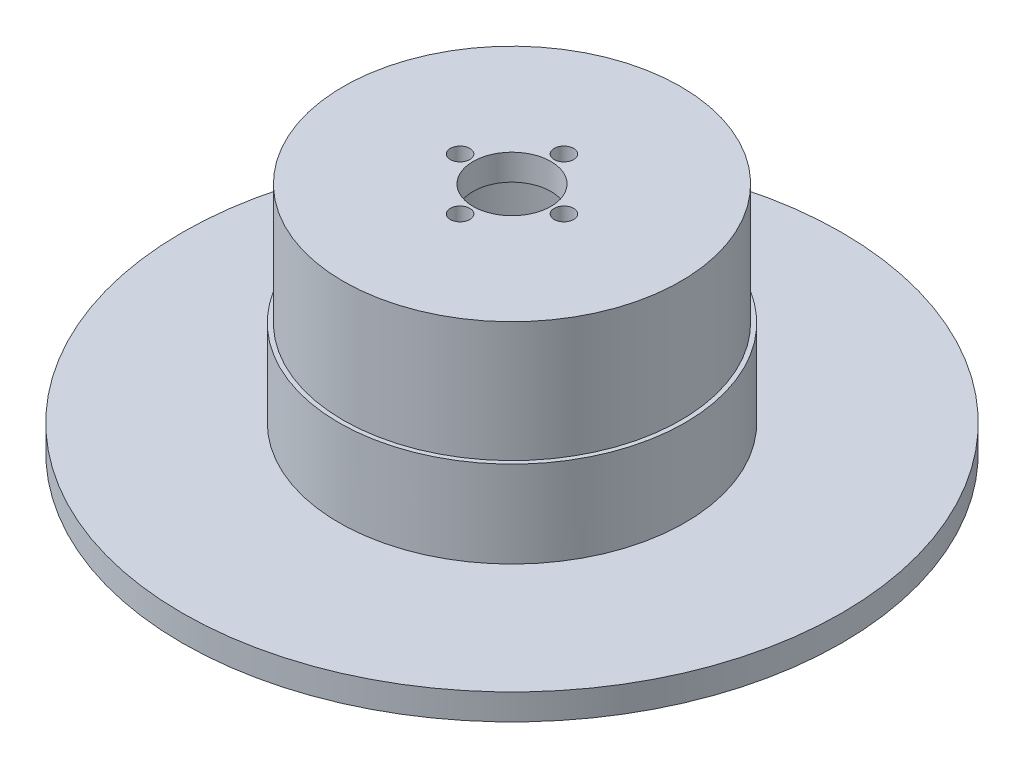
from build123d import *

# Parameters (mm, degrees)
SKETCH1_R           = 19.5
SKETCH1_R_2         = 14.5
BOSS_EXTRUDE1_DEPTH = 23.9
SKETCH2_R           = 38.1
SKETCH2_R_2         = 19.5
BOSS_EXTRUDE2_DEPTH = 3
SKETCH3_R           = 20
SKETCH3_R_2         = 19.5
BOSS_EXTRUDE3_DEPTH = 10
SKETCH4_R           = 19.5
SKETCH4_R_2         = 4.5
SKETCH4_R_3         = 1.125
BOSS_EXTRUDE4_DEPTH = 3


with BuildPart() as part:
    # Sketch1 → Boss-Extrude1 (new body)
    with BuildSketch(Plane(origin=(0, 0, 0), x_dir=(1, 0, 0), z_dir=(0, 1, 0))):
        Circle(SKETCH1_R)
        Circle(SKETCH1_R_2, mode=Mode.SUBTRACT)
    extrude(amount=BOSS_EXTRUDE1_DEPTH)

    # Sketch2 → Boss-Extrude2 (add)
    with BuildSketch(Plane.XZ):
        Circle(SKETCH2_R)
        Circle(SKETCH2_R_2, mode=Mode.SUBTRACT)
    extrude(amount=-BOSS_EXTRUDE2_DEPTH)

    # Sketch3 → Boss-Extrude3 (add)
    with BuildSketch(Plane(origin=(0, 3, 0), x_dir=(1, 0, 0), z_dir=(0, 1, 0))):
        Circle(SKETCH3_R)
        Circle(SKETCH3_R_2, mode=Mode.SUBTRACT)
    extrude(amount=BOSS_EXTRUDE3_DEPTH)

    # Sketch4 → Boss-Extrude4 (add)
    with BuildSketch(Plane(origin=(0, 23.9, 0), x_dir=(1, 0, 0), z_dir=(0, 1, 0))):
        Circle(SKETCH4_R)
        Circle(SKETCH4_R_2, mode=Mode.SUBTRACT)
        with Locations((0, 6)):
            Circle(SKETCH4_R_3, mode=Mode.SUBTRACT)
        with Locations((6, 0)):
            Circle(SKETCH4_R_3, mode=Mode.SUBTRACT)
        with Locations((0, -6)):
            Circle(SKETCH4_R_3, mode=Mode.SUBTRACT)
        with Locations((-6, 0)):
            Circle(SKETCH4_R_3, mode=Mode.SUBTRACT)
    extrude(amount=BOSS_EXTRUDE4_DEPTH)


solid = part.part
